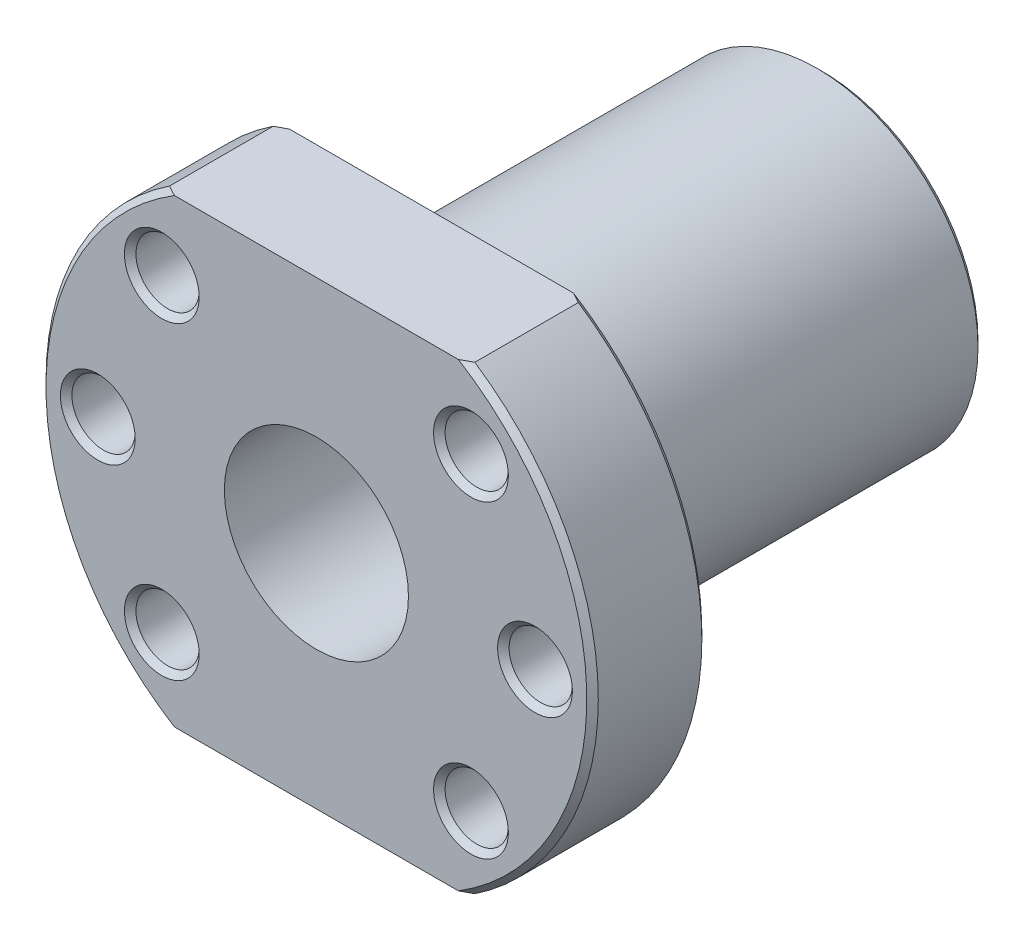
from build123d import *

# Parameters (mm, degrees)
SKETCH1_R                = 24
BOSS_EXTRUDE1_DEPTH      = 10
SKETCH2_R                = 14
BOSS_EXTRUDE2_DEPTH      = 34
CUT_EXTRUDE1_REACH       = 46
SKETCH3_W                = 82.684433326
SKETCH3_H                = 23.530230521
SKETCH3_W_2              = 72.226300178
SKETCH3_H_2              = 23.293039824
CUT_EXTRUDE2_REACH       = 46
SKETCH4_R                = 8
SKETCH7_R                = 2.75
CUT_EXTRUDE3_DEPTH       = 10
CHAMFER1_SIZE            = 0.5
CHAMFER1_OF_MIRROR1_SIZE = 0.5
CHAMFER2_SIZE            = 0.5


with BuildPart() as part:
    # Sketch1 → Boss-Extrude1 (new body)
    with BuildSketch(Plane.XY):
        Circle(SKETCH1_R)
    extrude(amount=BOSS_EXTRUDE1_DEPTH)

    # Sketch2 → Boss-Extrude2 (add)
    with BuildSketch(Plane(origin=(0, 0, 0), x_dir=(-1, 0, 0), z_dir=(0, 0, -1))):
        Circle(SKETCH2_R)
    extrude(amount=BOSS_EXTRUDE2_DEPTH)

    # Sketch3 → Cut-Extrude1 (cut, up to next)
    with BuildSketch(Plane.XY.offset(10), mode=Mode.PRIVATE) as cut_extrude1_sk1:
        with Locations((-2.888944578, 31.765115261)):
            Rectangle(SKETCH3_W, SKETCH3_H)
    cut_extrude1_tool1 = extrude(cut_extrude1_sk1.sketch, amount=-CUT_EXTRUDE1_REACH, mode=Mode.PRIVATE) & part.part
    add(cut_extrude1_tool1.solids().sort_by_distance((-2.888945, 31.765115, 10))[0], mode=Mode.SUBTRACT)
    # Sketch3 → Cut-Extrude1 (cut, up to next)
    with BuildSketch(Plane.XY.offset(10), mode=Mode.PRIVATE) as cut_extrude1_sk2:
        with Locations((2.340121996, -31.646519912)):
            Rectangle(SKETCH3_W_2, SKETCH3_H_2)
    cut_extrude1_tool2 = extrude(cut_extrude1_sk2.sketch, amount=-CUT_EXTRUDE1_REACH, mode=Mode.PRIVATE) & part.part
    add(cut_extrude1_tool2.solids().sort_by_distance((2.340122, -31.64652, 10))[0], mode=Mode.SUBTRACT)

    # Sketch4 → Cut-Extrude2 (cut, up to next)
    with BuildSketch(Plane(origin=(0, 0, -34), x_dir=(-1, 0, 0), z_dir=(0, 0, -1)), mode=Mode.PRIVATE) as cut_extrude2_sk1:
        Circle(SKETCH4_R)
    cut_extrude2_tool1 = extrude(cut_extrude2_sk1.sketch, amount=-CUT_EXTRUDE2_REACH, mode=Mode.PRIVATE) & part.part
    add(cut_extrude2_tool1.solids().sort_by_distance((0, 0, -34))[0], mode=Mode.SUBTRACT)

    # Sketch7 → Cut-Extrude3 (cut)
    with BuildSketch(Plane.XY.offset(10)):
        with Locations((-13.435028843, 13.435028843)):
            Circle(SKETCH7_R)
        with Locations((-19, 0)):
            Circle(SKETCH7_R)
        with Locations((-13.435028843, -13.435028843)):
            Circle(SKETCH7_R)
    cut_extrude3 = extrude(amount=-CUT_EXTRUDE3_DEPTH, mode=Mode.SUBTRACT)

    # Chamfer1
    chamfer1_edges = [part.edges().sort_by_distance(p)[0] for p in [
        (-16.185028843, 13.435028843, 10),
        (-21.75, 0, 10),
        (-16.185028843, -13.435028843, 10),
    ]]
    chamfer(chamfer1_edges, length=CHAMFER1_SIZE)

    # Mirror1: Cut-Extrude3 across plane
    add(cut_extrude3.mirror(Plane(origin=(0, 0, 0), x_dir=(0, 0, 1), z_dir=(1, 0, 0))), mode=Mode.SUBTRACT)

    # Chamfer1 of Mirror1
    chamfer1_of_mirror1_edges = [part.edges().sort_by_distance(p)[0] for p in [
        (16.185028843, 13.435028843, 10),
        (21.75, 0, 10),
        (16.185028843, -13.435028843, 10),
    ]]
    chamfer(chamfer1_of_mirror1_edges, length=CHAMFER1_OF_MIRROR1_SIZE)

    # Chamfer2
    chamfer2_edges = [part.edges().sort_by_distance(p)[0] for p in [
        (-24, 0, 0),
        (24, 0, 10),
        (24, 0, 0),
        (14, 0, -34),
        (-24, 0, 10),
    ]]
    chamfer(chamfer2_edges, length=CHAMFER2_SIZE)


solid = part.part
